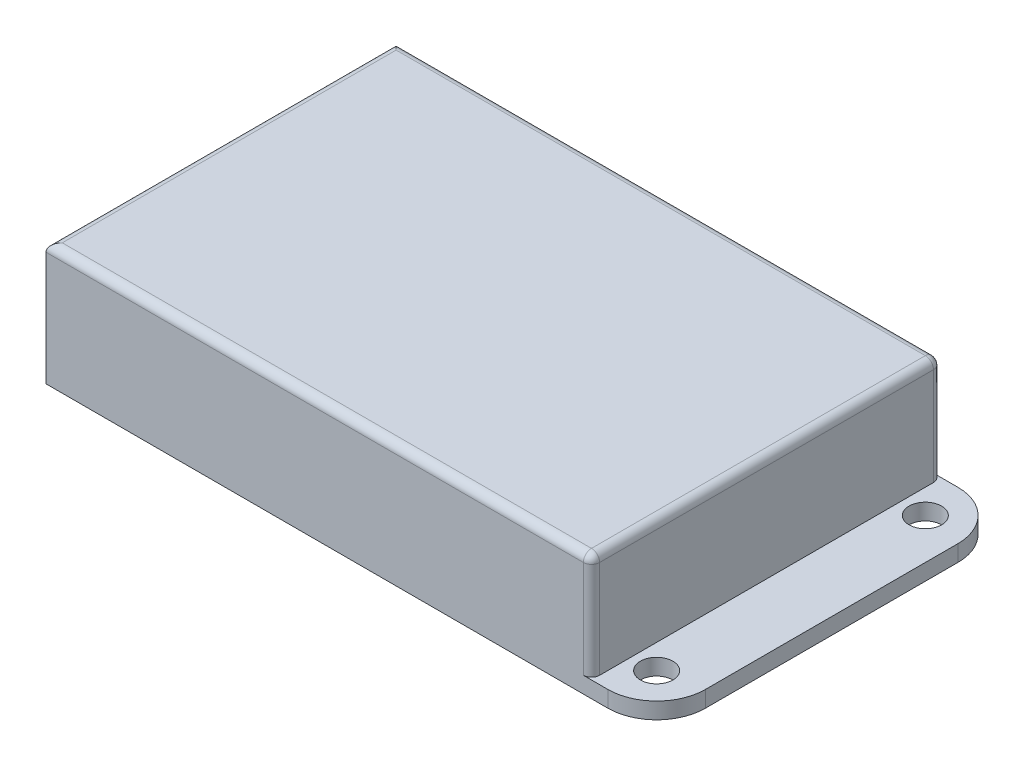
from build123d import *

# Parameters (mm, degrees)
BOSS_EXTRUDE1_DEPTH = 2
SKETCH2_W           = 67
SKETCH2_H           = 43
BOSS_EXTRUDE2_DEPTH = 13
SKETCH3_R           = 2
CUT_EXTRUDE1_DEPTH  = 3.0000001
FILLET1_R           = 6
FILLET2_R           = 1


with BuildPart() as part:
    # Sketch1 → Boss-Extrude1 (new body)
    with BuildSketch(Plane(origin=(0, 0, 0), x_dir=(1, 0, 0), z_dir=(0, 1, 0))):
        with BuildLine():
            Line((85, 0), (10, 0))
            add(Edge.make_bspline(
                [(10, 0), (7e-09, -10.749999992), (0, -21.499999985)],
                knots=[0, 0, 0, 0.5, 0.5, 0.5], degree=2))
            add(Edge.make_bspline(
                [(0, -21.499999985), (-7e-09, -32.249999992), (10, -43)],
                knots=[0.5, 0.5, 0.5, 1, 1, 1], degree=2))
            Line((10, -43), (85, -43))
            Line((85, -43), (85, 0))
        make_face()
    extrude(amount=BOSS_EXTRUDE1_DEPTH)

    # Sketch2 → Boss-Extrude2 (add)
    with BuildSketch(Plane(origin=(0, 2, 0), x_dir=(1, 0, 0), z_dir=(0, 1, 0))):
        with Locations((43.5, -21.5)):
            Rectangle(SKETCH2_W, SKETCH2_H)
    extrude(amount=BOSS_EXTRUDE2_DEPTH)

    # Sketch3 → Cut-Extrude1 (cut, through all)
    with BuildSketch(Plane(origin=(0, 2, 0), x_dir=(1, 0, 0), z_dir=(0, 1, 0))):
        with Locations((80, -5)):
            Circle(SKETCH3_R)
        with Locations((80, -38)):
            Circle(SKETCH3_R)
        with Locations((5, -21.500000001)):
            Circle(SKETCH3_R)
    extrude(amount=-CUT_EXTRUDE1_DEPTH, mode=Mode.SUBTRACT)

    # Fillet1
    fillet1_edges = [part.edges().sort_by_distance(p)[0] for p in [
        (85, 1, 0),
        (85, 1, 43),
    ]]
    fillet(fillet1_edges, radius=FILLET1_R)

    # Fillet2
    fillet2_edges = [part.edges().sort_by_distance(p)[0] for p in [
        (77, 8.5, 43),
        (77, 8.5, 0),
        (10, 15, 21.5),
        (43.5, 15, 43),
        (77, 15, 21.5),
        (43.5, 15, 0),
    ]]
    fillet(fillet2_edges, radius=FILLET2_R)


solid = part.part
